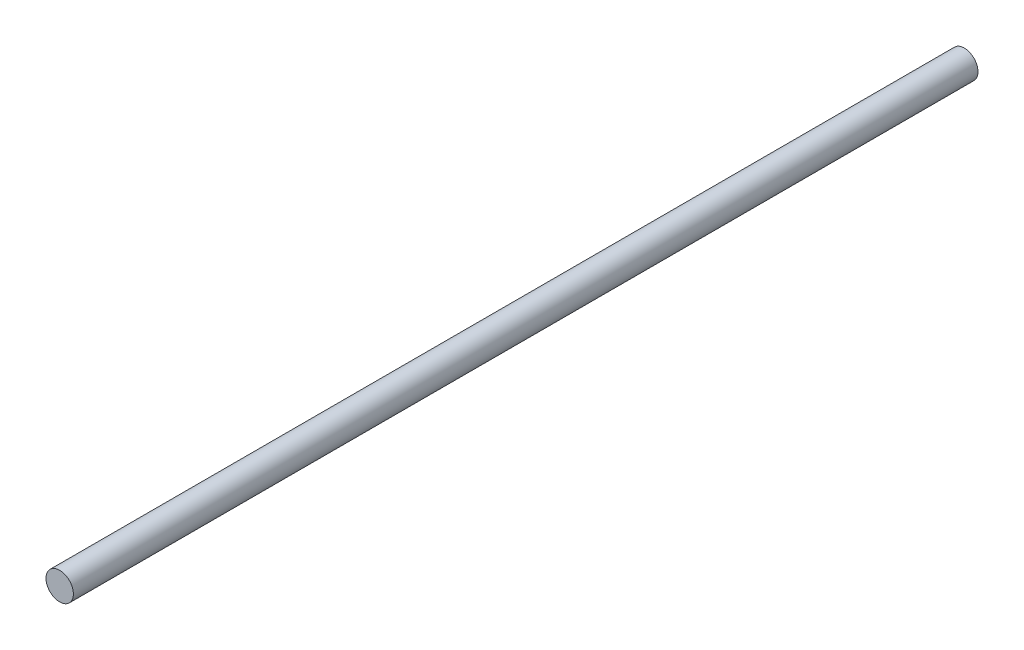
from build123d import *

# Parameters (mm, degrees)
SKETCH1_R           = 2.5
BOSS_EXTRUDE1_DEPTH = 165


with BuildPart() as part:
    # Sketch1 → Boss-Extrude1 (new body)
    with BuildSketch(Plane.XY):
        Circle(SKETCH1_R)
    extrude(amount=BOSS_EXTRUDE1_DEPTH)


solid = part.part
